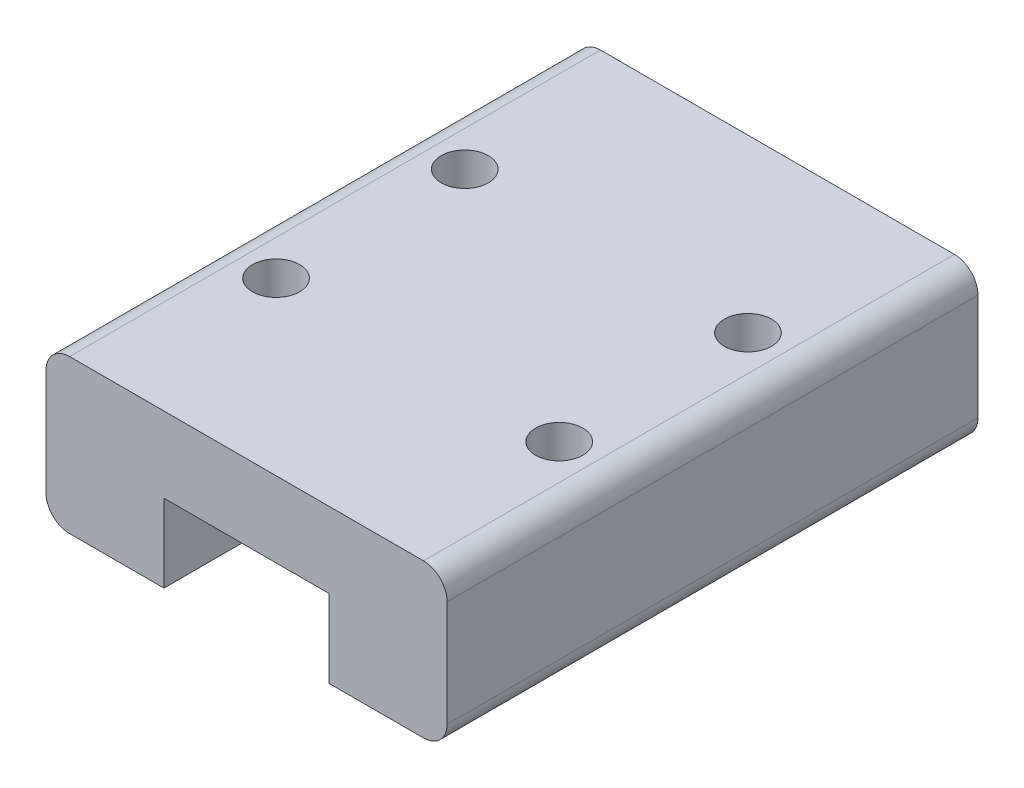
from build123d import *

# Parameters (mm, degrees)
EXTRUDE_1_DEPTH     = 22.5
SKETCH_2_R          = 1
CUT_EXTRUDE_1_DEPTH = 2.5


with BuildPart() as part:
    # 草图1 → 凸台-拉伸1 (new body)
    with BuildSketch(Plane.XY):
        with BuildLine():
            Line((5, 3.3), (12, 3.3))
            Line((12, 3.3), (12, 0))
            Line((12, 0), (16, 0))
            ThreePointArc((16, 0), (16.707106781, 0.292893219), (17, 1))
            Line((17, 1), (17, 5.5))
            ThreePointArc((17, 5.5), (16.707106781, 6.207106781), (16, 6.5))
            Line((16, 6.5), (1, 6.5))
            ThreePointArc((1, 6.5), (0.292893219, 6.207106781), (0, 5.5))
            Line((0, 5.5), (0, 1))
            ThreePointArc((0, 1), (0.292893219, 0.292893219), (1, 0))
            Line((1, 0), (5, 0))
            Line((5, 0), (5, 3.3))
        make_face()
    extrude(amount=EXTRUDE_1_DEPTH)

    # 草图2 → 切除-拉伸1 (cut)
    with BuildSketch(Plane(origin=(0, 6.5, 0), x_dir=(1, 0, 0), z_dir=(0, 1, 0))):
        with Locations((2.5, -15.25)):
            Circle(SKETCH_2_R)
        with Locations((2.5, -7.25)):
            Circle(SKETCH_2_R)
        with Locations((14.5, -7.25)):
            Circle(SKETCH_2_R)
        with Locations((14.5, -15.25)):
            Circle(SKETCH_2_R)
    extrude(amount=-CUT_EXTRUDE_1_DEPTH, mode=Mode.SUBTRACT)


solid = part.part
